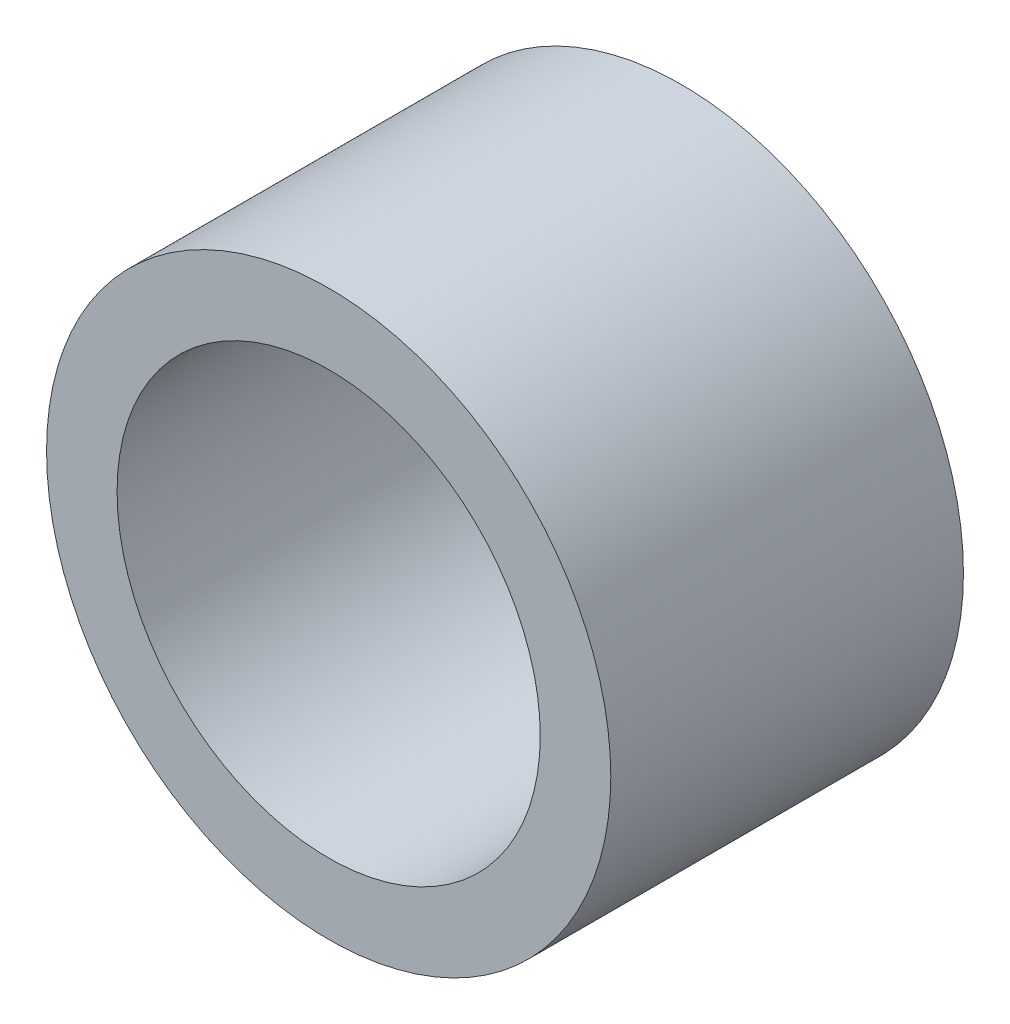
from build123d import *

# Parameters (mm, degrees)
SKETCH_1_R      = 4
SKETCH_1_R_2    = 3
EXTRUDE_1_DEPTH = 5


with BuildPart() as part:
    # 草图1 → 凸台-拉伸1 (new body)
    with BuildSketch(Plane.XY):
        Circle(SKETCH_1_R)
        Circle(SKETCH_1_R_2, mode=Mode.SUBTRACT)
    extrude(amount=EXTRUDE_1_DEPTH)


solid = part.part
